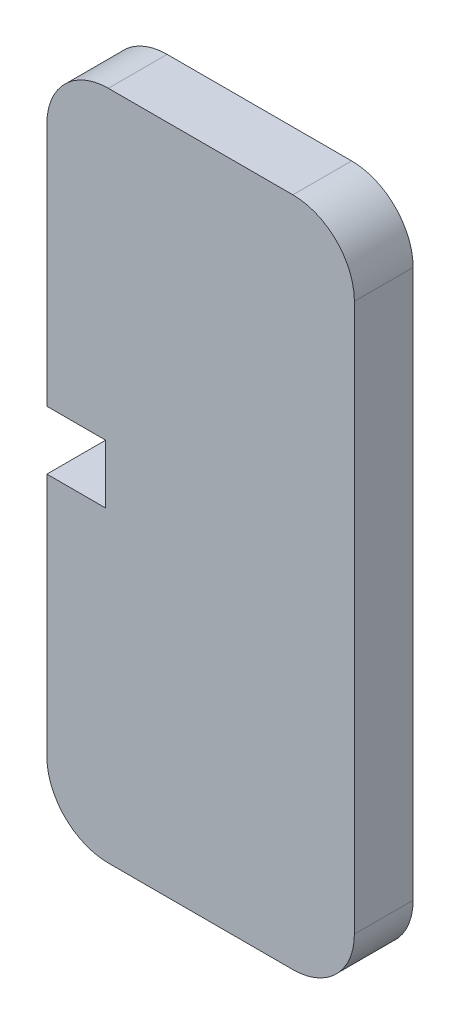
from build123d import *

# Parameters (mm, degrees)
BOSS_EXTRUDE1_DEPTH = 4.7752
SKETCH4_W           = 4.7752
SKETCH4_H           = 4.7752
CUT_EXTRUDE1_DEPTH  = 5.7752


with BuildPart() as part:
    # Sketch1 → Boss-Extrude1 (new body)
    with BuildSketch(Plane.XY):
        with BuildLine():
            Line((-4.5504, 44.7752), (-4.5504, 0.2248))
            ThreePointArc((-4.5504, 0.2248), (-3.085933906, -3.310733906), (0.4496, -4.7752))
            Line((0.4496, -4.7752), (15.4496, -4.7752))
            ThreePointArc((15.4496, -4.7752), (18.985133906, -3.310733906), (20.4496, 0.2248))
            Line((20.4496, 0.2248), (20.4496, 44.7752))
            ThreePointArc((20.4496, 44.7752), (18.985133906, 48.310733906), (15.4496, 49.7752))
            Line((15.4496, 49.7752), (0.4496, 49.7752))
            ThreePointArc((0.4496, 49.7752), (-3.085933906, 48.310733906), (-4.5504, 44.7752))
        make_face()
    extrude(amount=BOSS_EXTRUDE1_DEPTH)

    # Sketch4 → Cut-Extrude1 (cut, through all)
    with BuildSketch(Plane.XY.offset(4.7752)):
        with Locations((-2.1628, 22.5)):
            Rectangle(SKETCH4_W, SKETCH4_H)
    extrude(amount=-CUT_EXTRUDE1_DEPTH, mode=Mode.SUBTRACT)


solid = part.part
